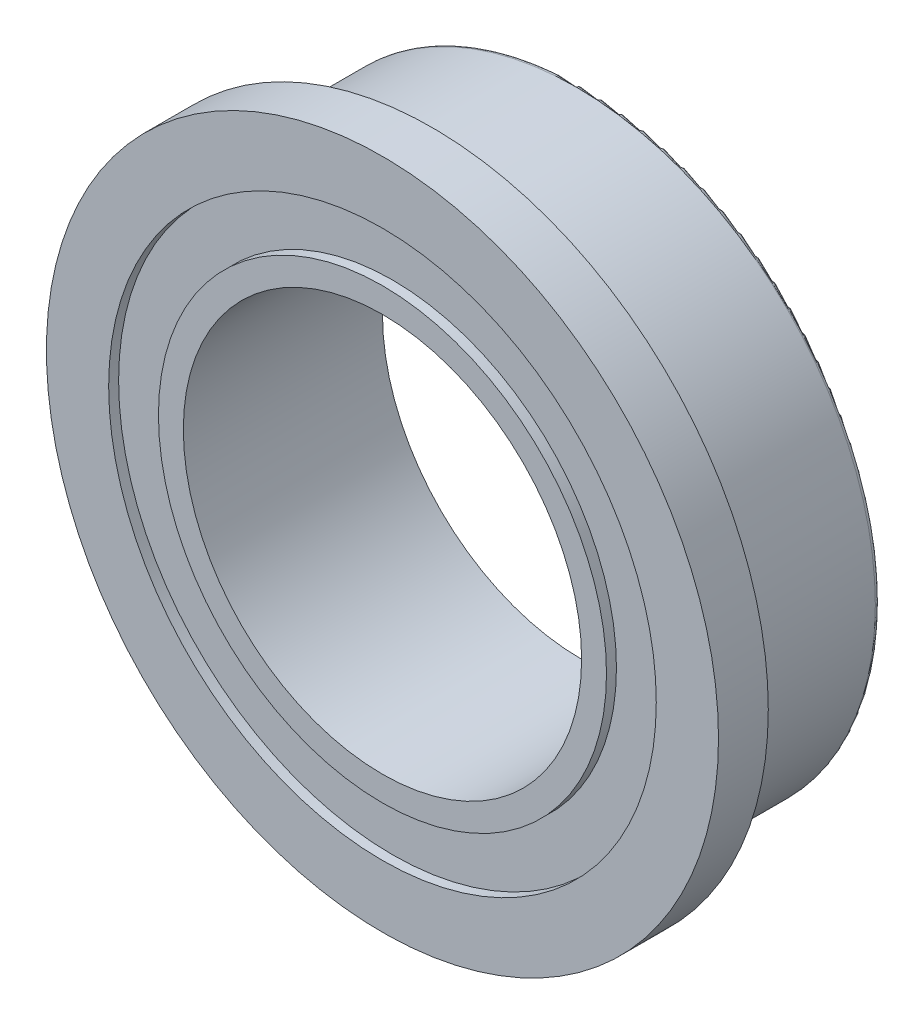
from build123d import *

# Parameters (mm, degrees)
SKETCH_1_R          = 6
EXTRUDE_1_DEPTH     = 4
SKETCH_2_R          = 6.75
EXTRUDE_2_DEPTH     = 1
SKETCH_3_R          = 4
CUT_EXTRUDE_1_DEPTH = 5
SKETCH_4_R          = 5.5
SKETCH_4_R_2        = 4.5
CUT_EXTRUDE_2_DEPTH = 0.2
SKETCH_5_R          = 5.5
SKETCH_5_R_2        = 4.5
CUT_EXTRUDE_3_DEPTH = 0.2
FILLET_1_R          = 0.1


with BuildPart() as part:
    # 草圖1 → 填料-伸長1 (new body)
    with BuildSketch(Plane.XY):
        Circle(SKETCH_1_R)
    extrude(amount=EXTRUDE_1_DEPTH)

    # 草圖2 → 填料-伸長2 (add)
    with BuildSketch(Plane.XY.offset(4)):
        Circle(SKETCH_2_R)
    extrude(amount=-EXTRUDE_2_DEPTH)

    # 草圖3 → 除料-伸長1 (cut, through all)
    with BuildSketch(Plane(origin=(0, 0, 0), x_dir=(-1, 0, 0), z_dir=(0, 0, -1))):
        Circle(SKETCH_3_R)
    extrude(amount=-CUT_EXTRUDE_1_DEPTH, mode=Mode.SUBTRACT)

    # 草圖4 → 除料-伸長2 (cut)
    with BuildSketch(Plane(origin=(0, 0, 0), x_dir=(-1, 0, 0), z_dir=(0, 0, -1))):
        Circle(SKETCH_4_R)
        Circle(SKETCH_4_R_2, mode=Mode.SUBTRACT)
    extrude(amount=-CUT_EXTRUDE_2_DEPTH, mode=Mode.SUBTRACT)

    # 草圖5 → 除料-伸長3 (cut)
    with BuildSketch(Plane.XY.offset(4)):
        Circle(SKETCH_5_R)
        Circle(SKETCH_5_R_2, mode=Mode.SUBTRACT)
    extrude(amount=-CUT_EXTRUDE_3_DEPTH, mode=Mode.SUBTRACT)

    # 圓角1
    fillet_1_edges = [part.edges().sort_by_distance(p)[0] for p in [
        (-6, 0, 0),
    ]]
    fillet(fillet_1_edges, radius=FILLET_1_R)


solid = part.part
